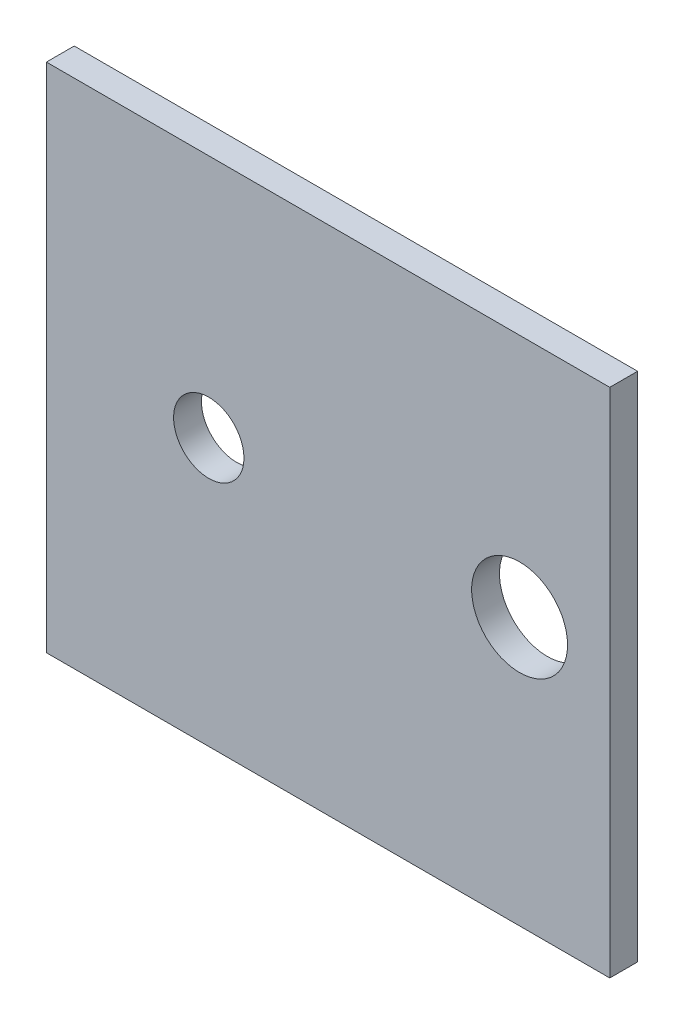
from build123d import *

# Parameters (mm, degrees)
CROQUIS1_W              = 88.1
CROQUIS1_H              = 80
SALIENTE_EXTRUIR1_DEPTH = 4.35
CROQUIS2_R              = 7.5
CROQUIS2_R_2            = 5.5
CORTAR_EXTRUIR1_DEPTH   = 5.35


with BuildPart() as part:
    # Croquis1 → Saliente-Extruir1 (new body)
    with BuildSketch(Plane.XY):
        with Locations((-10.777735365, 8.151223582)):
            Rectangle(CROQUIS1_W, CROQUIS1_H)
    extrude(amount=SALIENTE_EXTRUIR1_DEPTH)

    # Croquis2 → Cortar-Extruir1 (cut, through all)
    with BuildSketch(Plane.XY.offset(4.35)):
        with Locations((19.172264635, 9.961223582)):
            Circle(CROQUIS2_R)
        with Locations((-29.437735365, 9.961223582)):
            Circle(CROQUIS2_R_2)
    extrude(amount=-CORTAR_EXTRUIR1_DEPTH, mode=Mode.SUBTRACT)


solid = part.part
